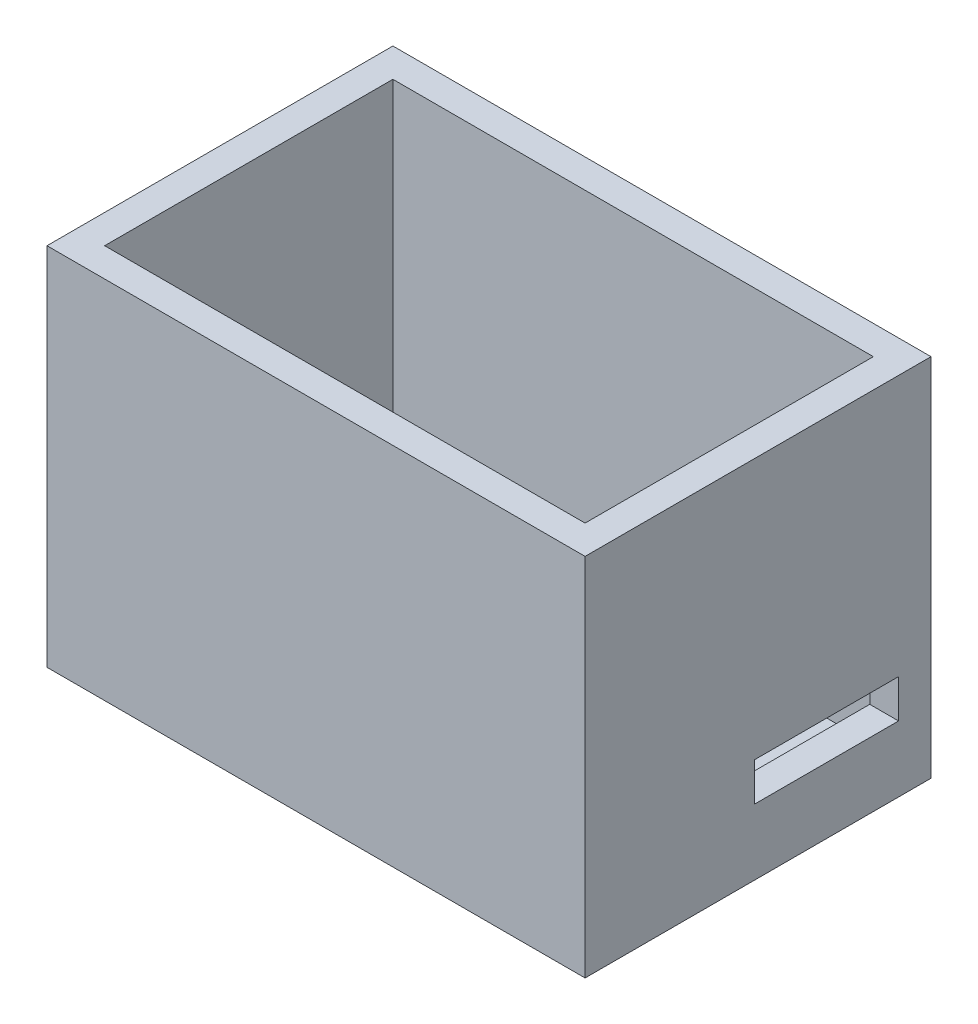
from build123d import *

# Parameters (mm, degrees)
ESBO_O1_W                = 50
ESBO_O1_H                = 30
RESSALTO_EXTRUS_O1_DEPTH = 35
CASCA1_T                 = 3
ESBO_O3_W                = 15
ESBO_O3_H                = 4
CORTE_EXTRUS_O2_DEPTH    = 35
ESBO_O4_R                = 2
CORTE_EXTRUS_O3_DEPTH    = 79.203795706


with BuildPart() as part:
    # Esboço1 → Ressalto-extrusão1 (new body)
    with BuildSketch(Plane(origin=(0, 0, 0), x_dir=(1, 0, 0), z_dir=(0, 1, 0))):
        with Locations((-35.335240137, 11.656045246)):
            Rectangle(ESBO_O1_W, ESBO_O1_H)
    extrude(amount=RESSALTO_EXTRUS_O1_DEPTH)

    # Casca1
    casca1_openings = [part.faces().sort_by_distance(p)[0] for p in [
        (-35.335240137, 35, -11.656045246),
    ]]
    offset(amount=CASCA1_T, openings=casca1_openings, kind=Kind.INTERSECTION)

    # Esboço3 → Corte-extrusão2 (cut)
    with BuildSketch(Plane(origin=(-7.335240137, 0, 0), x_dir=(0, 0, -1), z_dir=(1, 0, 0))):
        with Locations((18.781461493, 5.852803371)):
            Rectangle(ESBO_O3_W, ESBO_O3_H)
    extrude(amount=-CORTE_EXTRUS_O2_DEPTH, mode=Mode.SUBTRACT)

    # Esboço4 → Corte-extrusão3 (cut, through all)
    with BuildSketch(Plane(origin=(0, 0, 0), x_dir=(1, 0, 0), z_dir=(0, 1, 0))):
        with Locations(Location((-44.228238168, 17.721247166, 0), (0, 0, 270))):
            Circle(ESBO_O4_R)
        with Locations(Location((-44.228238168, 5.590843326, 0), (0, 0, 90))):
            Circle(ESBO_O4_R)
        with Locations(Location((-26.442242107, 5.590843326, 0), (0, 0, 270))):
            Circle(ESBO_O4_R)
        with Locations(Location((-26.442242107, 17.721247166, 0), (0, 0, 90))):
            Circle(ESBO_O4_R)
    extrude(amount=-CORTE_EXTRUS_O3_DEPTH, mode=Mode.SUBTRACT)


solid = part.part
